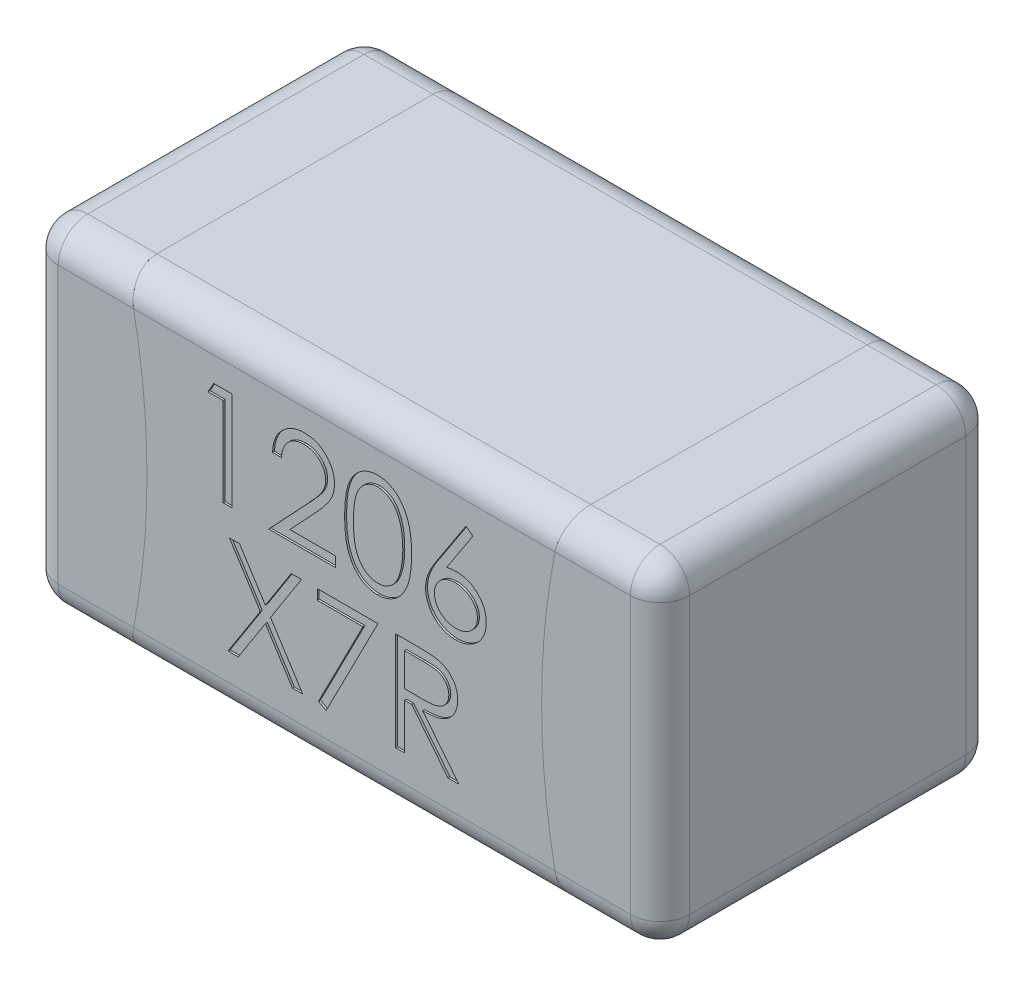
from build123d import *

# Parameters (mm, degrees)
EXTRUDE_1_DEPTH     = 1.7
EXTRUDE_1_2_DEPTH   = 1.7
EXTRUDE_2_DEPTH     = 1.7
FILLET_1_R          = 0.15
FILLET_2_R          = 0.15
FILLET_3_R          = 0.15
CUT_EXTRUDE_1_DEPTH = 0.01


with BuildPart() as part:
    # Эскиз1 → Бобышка-Вытянуть1 (new body)
    with BuildSketch(Plane.XY):
        with BuildLine():
            Line((-1.1, 0.85), (-1.6, 0.85))
            Line((-1.6, 0.85), (-1.6, -0.85))
            Line((-1.6, -0.85), (-1.1, -0.85))
            ThreePointArc((-1.1, -0.85), (-1, 0), (-1.1, 0.85))
        make_face()
    extrude(amount=EXTRUDE_1_DEPTH)

    # Скругление2
    fillet_2_edges = [part.edges().sort_by_distance(p)[0] for p in [
        (-1.6, 0.85, 0.85),
        (-1.6, 0, 1.7),
        (-1.6, -0.85, 0.85),
        (-1.6, 0, 0),
        (-1.35, 0.85, 0),
        (-1.35, -0.85, 0),
        (-1.35, 0.85, 1.7),
        (-1.35, -0.85, 1.7),
    ]]
    fillet(fillet_2_edges, radius=FILLET_2_R)


with BuildPart() as body_2:
    # Эскиз1 → Extrude 1 2 (new body)
    with BuildSketch(Plane.XY):
        with BuildLine():
            Line((1.6, 0.85), (1.1, 0.85))
            ThreePointArc((1.1, 0.85), (1, 0), (1.1, -0.85))
            Line((1.1, -0.85), (1.6, -0.85))
            Line((1.6, -0.85), (1.6, 0.85))
        make_face()
    extrude(amount=EXTRUDE_1_2_DEPTH)

    # Скругление1
    fillet_1_edges = [body_2.edges().sort_by_distance(p)[0] for p in [
        (1.6, -0.85, 0.85),
        (1.6, 0, 1.7),
        (1.6, 0.85, 0.85),
        (1.6, 0, 0),
        (1.35, -0.85, 0),
        (1.35, -0.85, 1.7),
        (1.35, 0.85, 0),
        (1.35, 0.85, 1.7),
    ]]
    fillet(fillet_1_edges, radius=FILLET_1_R)


with BuildPart() as body_3:
    # Эскиз1<3> → Бобышка-Вытянуть2 (new body)
    with BuildSketch(Plane.XY):
        with BuildLine():
            Line((1.1, 0.85), (-1.1, 0.85))
            ThreePointArc((-1.1, 0.85), (-1, 0), (-1.1, -0.85))
            Line((-1.1, -0.85), (1.1, -0.85))
            ThreePointArc((1.1, -0.85), (1, 0), (1.1, 0.85))
        make_face()
    extrude(amount=EXTRUDE_2_DEPTH)

    # Скругление3
    fillet_3_edges = [body_3.edges().sort_by_distance(p)[0] for p in [
        (0, -0.85, 1.7),
        (0, -0.85, 0),
        (0, 0.85, 1.7),
        (0, 0.85, 0),
    ]]
    fillet(fillet_3_edges, radius=FILLET_3_R)

    # Эскиз2 → Вырез-Вытянуть1 (cut)
    # profile 1 of 7: a face of its own
    with BuildSketch(Plane.XY.offset(1.7)):
        Polygon((-0.66134935, 0.575439945), (-0.568901434, 0.575439945), (-0.568901434, 0.075439945), (-0.613773229, 0.075439945), (-0.613773229, 0.524157894), (-0.690696305, 0.524157894), align=None)
    # profile 2 of 7: a face of its own
    with BuildSketch(Plane.XY.offset(1.7)):
        with BuildLine():
            Line((-0.318901434, 0.421593791), (-0.363773229, 0.421593791))
            add(Edge.make_bspline(
                [(-0.363773229, 0.421593791), (-0.363480778, 0.427546775), (-0.362906413, 0.439238277), (-0.360216658, 0.456284549), (-0.356367961, 0.472578092), (-0.350926325, 0.48798808), (-0.344168285, 0.502650767), (-0.336063995, 0.516507912), (-0.326464874, 0.529506653), (-0.315578198, 0.541526488), (-0.303754106, 0.552553283), (-0.290996115, 0.562075461), (-0.277589682, 0.570120843), (-0.263575483, 0.576846734), (-0.248795402, 0.581895284), (-0.233383565, 0.585641232), (-0.21727226, 0.587894996), (-0.206295114, 0.588137251), (-0.200712331, 0.588260458)],
                knots=[0, 0, 0, 0, 1.10065271, 2.161652631, 3.183658789, 4.190468796, 5.17591951, 6.163126047, 7.15150782, 8.156236427, 9.156009102, 10.134482811, 11.092018607, 12.041330605, 13.001268258, 13.972401359, 14.968799086, 16, 16, 16, 16], degree=3))
            add(Edge.make_bspline(
                [(-0.200712331, 0.588260458), (-0.195229749, 0.588132107), (-0.184456671, 0.587879902), (-0.168733526, 0.58571404), (-0.153765341, 0.582321813), (-0.139581375, 0.577562468), (-0.126294794, 0.571164693), (-0.113805788, 0.56347933), (-0.101965672, 0.554590783), (-0.09130756, 0.544125952), (-0.081520692, 0.532954183), (-0.073077512, 0.521027339), (-0.06584706, 0.50870887), (-0.059820249, 0.495904841), (-0.055383658, 0.482494694), (-0.052015342, 0.468673665), (-0.050111426, 0.454298692), (-0.049819223, 0.444569184), (-0.049670664, 0.439622637)],
                knots=[0, 0, 0, 0, 1.111607364, 2.184268762, 3.212621178, 4.221274766, 5.211760367, 6.196651075, 7.1921475, 8.207485113, 9.220403448, 10.201281604, 11.166441695, 12.114753415, 13.065576456, 14.026450734, 14.996634279, 16, 16, 16, 16], degree=3))
            add(Edge.make_bspline(
                [(-0.049670664, 0.439622637), (-0.049912559, 0.432658661), (-0.050392104, 0.418852916), (-0.054494157, 0.398565078), (-0.060900802, 0.378908876), (-0.06861471, 0.363089261), (-0.076396488, 0.350341619), (-0.083408989, 0.33984609), (-0.091618248, 0.328545309), (-0.101143747, 0.316477118), (-0.111788443, 0.303546988), (-0.123648752, 0.289762732), (-0.13680925, 0.275266765), (-0.146046178, 0.265365965), (-0.150832523, 0.260235618)],
                knots=[0, 0, 0, 0, 1.184426356, 2.348067706, 3.509069118, 4.696110526, 5.333549288, 6.050745305, 6.844228056, 7.710549037, 8.667450064, 9.695053472, 10.805634456, 12, 12, 12, 12], degree=3))
            Line((-0.150832523, 0.260235618), (-0.275932684, 0.126721996))
            Line((-0.275932684, 0.126721996), (-0.043260408, 0.126721996))
            Line((-0.043260408, 0.126721996), (-0.043260408, 0.075439945))
            Line((-0.043260408, 0.075439945), (-0.383003998, 0.075439945))
            Line((-0.383003998, 0.075439945), (-0.189093741, 0.282371035))
            add(Edge.make_bspline(
                [(-0.189093741, 0.282371035), (-0.184372615, 0.287299364), (-0.175304297, 0.296765676), (-0.162478214, 0.310586099), (-0.150958359, 0.323407462), (-0.14067016, 0.335205541), (-0.131836802, 0.346152907), (-0.123997912, 0.355895008), (-0.117717113, 0.364859929), (-0.110900628, 0.375251446), (-0.10429863, 0.38793892), (-0.098625437, 0.403443732), (-0.095166173, 0.419404768), (-0.094751196, 0.430190774), (-0.094542459, 0.435616227)],
                knots=[0, 0, 0, 0, 1.329631726, 2.553950428, 3.673215718, 4.687767853, 5.603093632, 6.413772471, 7.123043292, 7.734684054, 8.834405432, 9.900288307, 10.943827018, 12, 12, 12, 12], degree=3))
            add(Edge.make_bspline(
                [(-0.094542459, 0.435616227), (-0.09463328, 0.439027855), (-0.094812269, 0.44575152), (-0.09639194, 0.455609485), (-0.098779155, 0.465118744), (-0.102199906, 0.474308547), (-0.106715155, 0.483086497), (-0.112211352, 0.49146328), (-0.11855279, 0.499561704), (-0.125888685, 0.507155032), (-0.133947474, 0.51410949), (-0.142460938, 0.520270074), (-0.151468096, 0.525418518), (-0.160930971, 0.529639018), (-0.17082318, 0.532949786), (-0.181163858, 0.535243869), (-0.191924432, 0.536684224), (-0.199272074, 0.536879106), (-0.203016017, 0.536978406)],
                knots=[0, 0, 0, 0, 0.991446411, 1.95395049, 2.89581595, 3.838931463, 4.798493298, 5.75982156, 6.748411868, 7.785213223, 8.824556874, 9.840280684, 10.836137867, 11.835679398, 12.848801643, 13.863922112, 14.911575587, 16, 16, 16, 16], degree=3))
            add(Edge.make_bspline(
                [(-0.203016017, 0.536978406), (-0.206926136, 0.536876259), (-0.214604964, 0.536675658), (-0.225879112, 0.53527242), (-0.236634223, 0.532851586), (-0.246897352, 0.529540633), (-0.256685864, 0.525332268), (-0.265952156, 0.520090591), (-0.274675426, 0.513835806), (-0.282872072, 0.506744298), (-0.290424069, 0.498848926), (-0.297059337, 0.490047503), (-0.302857053, 0.480500729), (-0.307915515, 0.470234365), (-0.312023471, 0.459155254), (-0.315162492, 0.447302724), (-0.317646328, 0.434728241), (-0.318476116, 0.426044658), (-0.318901434, 0.421593791)],
                knots=[0, 0, 0, 0, 1.031018746, 2.02475058, 2.990194455, 3.934040569, 4.864654155, 5.795059489, 6.735614925, 7.690564532, 8.649604399, 9.611025574, 10.590972636, 11.591080095, 12.624614302, 13.701020113, 14.821632451, 16, 16, 16, 16], degree=3))
        make_face()
    # profile 3 of 7: a face of its own
    with BuildSketch(Plane.XY.offset(1.7)):
        with BuildLine():
            add(Edge.make_bspline(
                [(0.001611387, 0.325239624), (0.001658247, 0.333253537), (0.001749272, 0.348820677), (0.002761904, 0.371504198), (0.004444096, 0.392784239), (0.006749435, 0.41266182), (0.00955486, 0.431142072), (0.01329993, 0.448175609), (0.017558902, 0.463841267), (0.022494965, 0.478190131), (0.028064649, 0.491415517), (0.034126687, 0.503761974), (0.040921657, 0.515210822), (0.048061216, 0.525944792), (0.055834369, 0.535788177), (0.064019911, 0.544879986), (0.072937322, 0.553010093), (0.082283466, 0.560416708), (0.092142961, 0.566909489), (0.10223477, 0.572628452), (0.112628357, 0.577514147), (0.123352097, 0.581355638), (0.134309605, 0.584528616), (0.145539186, 0.586698466), (0.157059381, 0.588063739), (0.164835301, 0.588194262), (0.168778855, 0.588260458)],
                knots=[0, 0, 0, 0, 1.646270934, 3.197905019, 4.663502075, 6.030701355, 7.308322542, 8.50163776, 9.611534131, 10.641858119, 11.616356847, 12.558055219, 13.465016945, 14.349605745, 15.204443733, 16.039544428, 16.859896111, 17.680448484, 18.487036065, 19.28249412, 20.06191084, 20.843045899, 21.620316918, 22.403196591, 23.190181807, 24, 24, 24, 24], degree=3))
            add(Edge.make_bspline(
                [(0.168778855, 0.588260458), (0.172755352, 0.58819077), (0.180663353, 0.588052183), (0.192354835, 0.586720191), (0.203776218, 0.58451003), (0.214878809, 0.581378462), (0.225753808, 0.577493366), (0.236316152, 0.572623778), (0.246631449, 0.566955368), (0.256535776, 0.560294814), (0.266137864, 0.552868775), (0.275201858, 0.544474108), (0.283728585, 0.535195576), (0.291825057, 0.525132453), (0.299261571, 0.514091727), (0.30634349, 0.502265425), (0.312682352, 0.48944673), (0.318787306, 0.47584952), (0.324056875, 0.461097569), (0.328809196, 0.445274032), (0.332649049, 0.428192005), (0.335847516, 0.409941113), (0.338325358, 0.39045433), (0.340130022, 0.369773428), (0.341083319, 0.3478848), (0.341262848, 0.332919393), (0.341354977, 0.325239624)],
                knots=[0, 0, 0, 0, 0.810914788, 1.612654377, 2.396697861, 3.181598691, 3.963628158, 4.749916497, 5.551656086, 6.361998678, 7.18212741, 8.025565596, 8.878627764, 9.750805457, 10.657531673, 11.591944965, 12.560506719, 13.57287815, 14.630710178, 15.753379473, 16.941251878, 18.199788006, 19.531962791, 20.947069417, 22.433333509, 24, 24, 24, 24], degree=3))
            add(Edge.make_bspline(
                [(0.341354977, 0.325239624), (0.341261893, 0.317593352), (0.341080524, 0.302694901), (0.340140708, 0.280904762), (0.338289475, 0.260333613), (0.335973763, 0.240932118), (0.332766482, 0.22278103), (0.328822887, 0.205817537), (0.32444427, 0.189968384), (0.319039299, 0.175363411), (0.313123483, 0.161798879), (0.306687027, 0.149132144), (0.299791337, 0.137251245), (0.292278659, 0.126251281), (0.284271029, 0.11605433), (0.275597059, 0.106840384), (0.266501261, 0.098387431), (0.256870916, 0.09086577), (0.246812123, 0.084282226), (0.236532255, 0.078394533), (0.225848914, 0.073647006), (0.215004207, 0.069570571), (0.203843012, 0.066456221), (0.192379242, 0.064302813), (0.180671208, 0.062792549), (0.172756699, 0.062677337), (0.168778855, 0.062619432)],
                knots=[0, 0, 0, 0, 1.561518951, 3.042555995, 4.452378317, 5.7783523, 7.031515105, 8.214008947, 9.334062868, 10.386615937, 11.391082383, 12.354592575, 13.286541444, 14.194233754, 15.072674879, 15.931287219, 16.775624067, 17.606195743, 18.42308326, 19.229000347, 20.022332153, 20.807536673, 21.593273796, 22.3848459, 23.188221202, 24, 24, 24, 24], degree=3))
            add(Edge.make_bspline(
                [(0.168778855, 0.062619432), (0.16483541, 0.062686054), (0.157059706, 0.06281742), (0.145537931, 0.064176525), (0.134354725, 0.066361597), (0.123454903, 0.069421111), (0.112782544, 0.073166088), (0.102483074, 0.078045186), (0.092441977, 0.083664338), (0.08268604, 0.090063684), (0.073398588, 0.097395353), (0.064527359, 0.105504537), (0.056295214, 0.114593596), (0.0486332, 0.124519014), (0.041351187, 0.135189477), (0.034652705, 0.146750673), (0.028456869, 0.15915676), (0.022793513, 0.17248789), (0.017772276, 0.186938594), (0.013336889, 0.202674191), (0.009834866, 0.219833568), (0.006837301, 0.238278906), (0.004419532, 0.258089468), (0.002768914, 0.279276007), (0.001748726, 0.301825323), (0.001658002, 0.317292434), (0.001611387, 0.325239624)],
                knots=[0, 0, 0, 0, 0.810891512, 1.598919785, 2.382837074, 3.152667961, 3.926044502, 4.706494248, 5.493654104, 6.291793342, 7.103789334, 7.925228297, 8.761435821, 9.622817696, 10.50288917, 11.416980706, 12.369136599, 13.353924996, 14.394355917, 15.514179734, 16.714354668, 17.994756427, 19.357759367, 20.818452758, 22.365282078, 24, 24, 24, 24], degree=3))
        make_face()
        with BuildLine():
            add(Edge.make_bspline(
                [(0.046483182, 0.325439945), (0.046500246, 0.318761559), (0.046533363, 0.305800124), (0.047398535, 0.286965373), (0.048577139, 0.269398183), (0.050097325, 0.253076249), (0.052354889, 0.238054819), (0.05488443, 0.224230578), (0.057962728, 0.211676687), (0.061604874, 0.200307), (0.065753316, 0.189928562), (0.070282725, 0.180271245), (0.075148543, 0.171220969), (0.080594136, 0.162859025), (0.086524859, 0.155158144), (0.092806753, 0.147982025), (0.099674265, 0.141582456), (0.1091748, 0.133907191), (0.121717153, 0.125975887), (0.137520076, 0.119069302), (0.153758426, 0.114728951), (0.164780033, 0.114176986), (0.170281259, 0.113901483)],
                knots=[0, 0, 0, 0, 1.459021318, 2.831673884, 4.118529203, 5.306027144, 6.411944654, 7.436330062, 8.375795394, 9.233974572, 10.042671642, 10.816086306, 11.563610507, 12.285937304, 12.993564865, 13.685989202, 14.367179055, 15.041617293, 16.353048772, 17.594441528, 18.799311195, 20, 20, 20, 20], degree=3))
            add(Edge.make_bspline(
                [(0.170281259, 0.113901483), (0.175818069, 0.114129738), (0.186880258, 0.114585775), (0.203042229, 0.118985595), (0.218732267, 0.125624101), (0.231028259, 0.133473744), (0.240382908, 0.14094922), (0.247085335, 0.147322741), (0.253237056, 0.154459293), (0.259071638, 0.162159193), (0.264422935, 0.170569548), (0.269289097, 0.179649916), (0.273729575, 0.189425512), (0.276259439, 0.196249761), (0.277552893, 0.199738823)],
                knots=[0, 0, 0, 0, 1.353760809, 2.704726607, 4.075137775, 5.516104923, 6.260822281, 7.007110065, 7.778089737, 8.566572457, 9.372053459, 10.217411131, 11.088608312, 12, 12, 12, 12], degree=3))
            add(Edge.make_bspline(
                [(0.277552893, 0.199738823), (0.279060289, 0.204200214), (0.282120948, 0.213258752), (0.286065487, 0.227310702), (0.289171973, 0.242053954), (0.291966739, 0.2574004), (0.293874318, 0.273463214), (0.29540972, 0.290192698), (0.296314104, 0.307601464), (0.296426212, 0.319429319), (0.296483182, 0.325439945)],
                knots=[0, 0, 0, 0, 0.884706709, 1.796334032, 2.740027952, 3.714592787, 4.726048262, 5.777819803, 6.87074269, 8, 8, 8, 8], degree=3))
            add(Edge.make_bspline(
                [(0.296483182, 0.325439945), (0.296404583, 0.331449598), (0.296250828, 0.343205764), (0.295663115, 0.360422647), (0.294145462, 0.376775185), (0.292459873, 0.392333824), (0.289974556, 0.407012438), (0.287294869, 0.42093391), (0.283694696, 0.433925771), (0.279849014, 0.446191426), (0.275447529, 0.457591519), (0.270602424, 0.468179203), (0.265427887, 0.478005592), (0.259807567, 0.487043727), (0.253808184, 0.49533409), (0.247271391, 0.502710461), (0.240456481, 0.509401456), (0.230911168, 0.517038966), (0.218414841, 0.524826351), (0.202865463, 0.531992888), (0.186683942, 0.536108359), (0.175744878, 0.5366886), (0.170281259, 0.536978406)],
                knots=[0, 0, 0, 0, 1.31362396, 2.569729283, 3.763502607, 4.902122613, 5.988968491, 7.01645872, 7.998833611, 8.933434873, 9.825090667, 10.667526885, 11.477055099, 12.250526234, 12.991942729, 13.710640831, 14.402115721, 15.076753259, 16.378508321, 17.609869233, 18.806226677, 20, 20, 20, 20], degree=3))
            add(Edge.make_bspline(
                [(0.170281259, 0.536978406), (0.164751174, 0.5366882), (0.15368093, 0.536107258), (0.137331223, 0.532008221), (0.121659172, 0.524863512), (0.10919589, 0.517013173), (0.099643921, 0.509536271), (0.092917822, 0.503052492), (0.086611226, 0.49596017), (0.080801554, 0.488188468), (0.075360228, 0.479836273), (0.070362941, 0.470837878), (0.065860465, 0.461147683), (0.061705531, 0.450773906), (0.058052276, 0.4394052), (0.055038852, 0.426866772), (0.052254988, 0.413086502), (0.050284235, 0.397983715), (0.04853227, 0.381657693), (0.047406363, 0.364046648), (0.046530469, 0.345180308), (0.04649926, 0.332151857), (0.046483182, 0.325439945)],
                knots=[0, 0, 0, 0, 1.207732386, 2.417664972, 3.655092373, 4.956220595, 5.625982001, 6.301752483, 6.994047911, 7.697131622, 8.419323945, 9.170223765, 9.943494443, 10.752040957, 11.610060368, 12.549350801, 13.567764191, 14.679664412, 15.874934091, 17.154273443, 18.533957287, 20, 20, 20, 20], degree=3))
        make_face(mode=Mode.SUBTRACT)
    # profile 4 of 7: a face of its own
    with BuildSketch(Plane.XY.offset(1.7)):
        with BuildLine():
            Line((0.616996002, 0.588260458), (0.651551291, 0.561117028))
            Line((0.651551291, 0.561117028), (0.519439912, 0.359093791))
            add(Edge.make_bspline(
                [(0.519439912, 0.359093791), (0.528235666, 0.360495771), (0.545392779, 0.363230492), (0.562759336, 0.363681627), (0.571222765, 0.363901483)],
                knots=[0, 0, 0, 0, 1.025318673, 2, 2, 2, 2], degree=3))
            add(Edge.make_bspline(
                [(0.571222765, 0.363901483), (0.57630455, 0.363764896), (0.586307893, 0.363496028), (0.600994579, 0.361426906), (0.615107284, 0.358166176), (0.628587515, 0.353412996), (0.641483655, 0.347341232), (0.653869711, 0.34006425), (0.665512856, 0.331206296), (0.676563024, 0.321311302), (0.686595467, 0.310351733), (0.69547776, 0.29872297), (0.702938731, 0.28643713), (0.708992148, 0.273500435), (0.713692845, 0.259932827), (0.717119651, 0.245751664), (0.719145307, 0.230947168), (0.719420378, 0.220878857), (0.719560105, 0.215764464)],
                knots=[0, 0, 0, 0, 1.04369286, 2.054478336, 3.041073146, 4.015093852, 4.984733326, 5.965804835, 6.960378782, 7.985147595, 9.009457201, 10.008161701, 10.986880575, 11.956520048, 12.937015923, 13.931873656, 14.949455224, 16, 16, 16, 16], degree=3))
            add(Edge.make_bspline(
                [(0.719560105, 0.215764464), (0.719356804, 0.208767364), (0.718956756, 0.194998726), (0.7149705, 0.17494491), (0.708776265, 0.155840265), (0.699922332, 0.137989812), (0.688924849, 0.121418017), (0.675513764, 0.106734379), (0.660164695, 0.093638659), (0.642809438, 0.082687713), (0.624131871, 0.07374442), (0.604510157, 0.067320814), (0.584134851, 0.063366033), (0.570305621, 0.062870233), (0.563310105, 0.062619432)],
                knots=[0, 0, 0, 0, 1.031375318, 2.029502543, 3.004789286, 3.987476834, 4.960371455, 5.9300674, 6.912260825, 7.929083631, 8.949397511, 9.960523116, 10.96833055, 12, 12, 12, 12], degree=3))
            add(Edge.make_bspline(
                [(0.563310105, 0.062619432), (0.556582005, 0.062837747), (0.543254816, 0.063270191), (0.523650131, 0.067122468), (0.504812558, 0.07336634), (0.486874075, 0.08196838), (0.470256844, 0.092833791), (0.455390325, 0.105914117), (0.442348643, 0.120929755), (0.431495125, 0.137878376), (0.422886735, 0.156091227), (0.416431031, 0.175082249), (0.41266014, 0.194782247), (0.412133203, 0.208136695), (0.411867797, 0.214863022)],
                knots=[0, 0, 0, 0, 1.012016664, 2.004627821, 2.994792927, 3.992885782, 4.990978636, 5.973936114, 6.964471063, 7.975201453, 8.993600317, 9.990122807, 10.98767138, 12, 12, 12, 12], degree=3))
            add(Edge.make_bspline(
                [(0.411867797, 0.214863022), (0.412036575, 0.220012248), (0.412381187, 0.230525984), (0.414787386, 0.246449416), (0.418653785, 0.262742428), (0.42298382, 0.276564456), (0.427558907, 0.28788753), (0.431366413, 0.2970166), (0.436105555, 0.30641104), (0.441158895, 0.316392988), (0.446981305, 0.326705192), (0.453312112, 0.337520002), (0.460326348, 0.34866542), (0.465243514, 0.356228877), (0.46775722, 0.360095394)],
                knots=[0, 0, 0, 0, 1.173818275, 2.396712641, 3.66331629, 4.989737886, 5.693666774, 6.447286557, 7.243889047, 8.091586357, 8.998013824, 9.943181721, 10.948533338, 12, 12, 12, 12], degree=3))
            Line((0.46775722, 0.360095394), (0.616996002, 0.588260458))
        make_face()
        with BuildLine():
            add(Edge.make_bspline(
                [(0.561807701, 0.312619432), (0.557998809, 0.312508283), (0.550558936, 0.312291176), (0.539643591, 0.311030426), (0.529313127, 0.308656274), (0.519430679, 0.305632512), (0.510181007, 0.301474932), (0.501496887, 0.296424675), (0.493344737, 0.290478793), (0.485809944, 0.28372152), (0.478978563, 0.276323229), (0.473095545, 0.268399012), (0.468020916, 0.26013984), (0.463894942, 0.251476705), (0.460682074, 0.24241292), (0.458358038, 0.23299017), (0.457064645, 0.223145269), (0.456849469, 0.216469197), (0.456739592, 0.213060137)],
                knots=[0, 0, 0, 0, 1.129588631, 2.206414736, 3.251139165, 4.268635594, 5.265702196, 6.250456724, 7.242448911, 8.251968645, 9.246821453, 10.222880186, 11.173611482, 12.116736599, 13.062300278, 14.020270554, 14.989073742, 16, 16, 16, 16], degree=3))
            add(Edge.make_bspline(
                [(0.456739592, 0.213060137), (0.456829072, 0.209681569), (0.45700453, 0.203056699), (0.458597718, 0.193293959), (0.461031301, 0.183898972), (0.464651358, 0.174920172), (0.468969485, 0.166220698), (0.474670245, 0.158115657), (0.480986929, 0.15011279), (0.488537491, 0.142826866), (0.496640828, 0.136047348), (0.505298143, 0.130121597), (0.514320995, 0.125052144), (0.523831198, 0.12107913), (0.533693824, 0.117818518), (0.543991046, 0.115524021), (0.554730025, 0.114226803), (0.562004588, 0.114011346), (0.565713951, 0.113901483)],
                knots=[0, 0, 0, 0, 0.989467248, 1.94019797, 2.891935182, 3.827694429, 4.772920941, 5.730924762, 6.725747692, 7.756678648, 8.79901574, 9.819492441, 10.826891316, 11.826466727, 12.835195252, 13.867842842, 14.912794438, 16, 16, 16, 16], degree=3))
            add(Edge.make_bspline(
                [(0.565713951, 0.113901483), (0.569423308, 0.114011355), (0.576697859, 0.114226828), (0.587436924, 0.115523924), (0.597733827, 0.117818873), (0.607597614, 0.12107784), (0.617103533, 0.125056928), (0.626118493, 0.130090059), (0.634693935, 0.13608379), (0.642802592, 0.14281528), (0.650321726, 0.150154259), (0.656789909, 0.158044219), (0.662316085, 0.166286204), (0.666806683, 0.174885903), (0.670386867, 0.183904401), (0.672832791, 0.193292504), (0.67442269, 0.203057079), (0.674598599, 0.209681697), (0.67468831, 0.213060137)],
                knots=[0, 0, 0, 0, 1.087397944, 2.132534446, 3.165364764, 4.174271784, 5.174024072, 6.181601208, 7.194203697, 8.236725232, 9.267838612, 10.269026844, 11.221737037, 12.171628256, 13.107553087, 14.05945871, 15.010357665, 16, 16, 16, 16], degree=3))
            add(Edge.make_bspline(
                [(0.67468831, 0.213060137), (0.674609697, 0.216473644), (0.674455404, 0.223173249), (0.672710269, 0.232985766), (0.67028993, 0.242460795), (0.666635211, 0.251538788), (0.661887133, 0.260183921), (0.656103789, 0.268439864), (0.649413422, 0.276369913), (0.641685202, 0.283736029), (0.633272312, 0.290471326), (0.624327228, 0.296416976), (0.614968946, 0.30143483), (0.605206954, 0.305621559), (0.5949294, 0.308642913), (0.584302208, 0.311021947), (0.573189459, 0.31228795), (0.565649944, 0.312507531), (0.561807701, 0.312619432)],
                knots=[0, 0, 0, 0, 0.978206639, 1.919901502, 2.851605144, 3.780102724, 4.718870031, 5.675451981, 6.667674623, 7.690630536, 8.733308323, 9.756129687, 10.767539656, 11.776269907, 12.797430371, 13.836405707, 14.897401972, 16, 16, 16, 16], degree=3))
        make_face(mode=Mode.SUBTRACT)
    # profile 5 of 7: a face of its own
    with BuildSketch(Plane.XY.offset(1.7)):
        Polygon((-0.582466305, -0.062820741), (-0.530683452, -0.062820741), (-0.399773997, -0.267347985), (-0.268864542, -0.062820741), (-0.217081689, -0.062820741), (-0.373832491, -0.307812728), (-0.210671433, -0.562820741), (-0.262454285, -0.562820741), (-0.399773997, -0.348277472), (-0.537093708, -0.562820741), (-0.588876561, -0.562820741), (-0.425615343, -0.307812728), align=None)
    # profile 6 of 7: a face of its own
    with BuildSketch(Plane.XY.offset(1.7)):
        Polygon((-0.136953484, -0.062820741), (0.170738824, -0.062820741), (-0.092081689, -0.575641254), (-0.130843708, -0.554307119), (0.094817349, -0.114102792), (-0.136953484, -0.114102792), align=None)
    # profile 7 of 7: a face of its own
    with BuildSketch(Plane.XY.offset(1.7)):
        with BuildLine():
            Line((0.260482413, -0.062820741), (0.360542509, -0.062820741))
            add(Edge.make_bspline(
                [(0.360542509, -0.062820741), (0.367219814, -0.062842968), (0.380040977, -0.062885645), (0.398408587, -0.063123611), (0.415098172, -0.063805662), (0.430101007, -0.064392603), (0.443416814, -0.06546288), (0.455086427, -0.06648583), (0.465056098, -0.067824924), (0.47109122, -0.069068556), (0.473823759, -0.069631639)],
                knots=[0, 0, 0, 0, 1.410062039, 2.707475311, 3.878576406, 4.937260626, 5.877586885, 6.699081471, 7.410979367, 8, 8, 8, 8], degree=3))
            add(Edge.make_bspline(
                [(0.473823759, -0.069631639), (0.477481849, -0.070535462), (0.48471999, -0.072323828), (0.495141428, -0.076103771), (0.505072046, -0.080478003), (0.514470592, -0.085615678), (0.523289991, -0.091554932), (0.531621178, -0.098193235), (0.539501959, -0.105494265), (0.54661362, -0.113642099), (0.553319199, -0.122190172), (0.558974717, -0.131433566), (0.563849928, -0.141099498), (0.567731431, -0.151286272), (0.570856855, -0.161895097), (0.573060604, -0.173022068), (0.574382202, -0.184616493), (0.574516753, -0.192524765), (0.574584977, -0.196534683)],
                knots=[0, 0, 0, 0, 1.027469482, 2.033020251, 3.019912614, 3.986113645, 4.951240523, 5.91722682, 6.890402269, 7.87763091, 8.8651537, 9.85103654, 10.82876324, 11.815024772, 12.821070561, 13.842952187, 14.906261191, 16, 16, 16, 16], degree=3))
            add(Edge.make_bspline(
                [(0.574584977, -0.196534683), (0.574375121, -0.203196841), (0.573965635, -0.216196437), (0.570147763, -0.235062277), (0.563893975, -0.25266075), (0.555276362, -0.268969699), (0.544302151, -0.283671219), (0.531112896, -0.296584142), (0.515701237, -0.307389843), (0.501354192, -0.314883101), (0.488680735, -0.319682088), (0.478247404, -0.323058711), (0.466866407, -0.325667563), (0.454646788, -0.328004725), (0.441537694, -0.329769252), (0.427570546, -0.331061623), (0.412735381, -0.331869344), (0.402544086, -0.331989631), (0.397301324, -0.33205151)],
                knots=[0, 0, 0, 0, 1.260483769, 2.459530307, 3.627416485, 4.787058657, 5.939039949, 7.08810263, 8.267026773, 9.491475466, 10.141966685, 10.831826277, 11.566392101, 12.351337768, 13.187381173, 14.07005841, 15.007169909, 16, 16, 16, 16], degree=3))
            Line((0.397301324, -0.33205151), (0.580995234, -0.562820741))
            Line((0.580995234, -0.562820741), (0.525506452, -0.562820741))
            Line((0.525506452, -0.562820741), (0.341812542, -0.33205151))
            Line((0.341812542, -0.33205151), (0.305354208, -0.33205151))
            Line((0.305354208, -0.33205151), (0.305354208, -0.562820741))
            Line((0.305354208, -0.562820741), (0.260482413, -0.562820741))
            Line((0.260482413, -0.562820741), (0.260482413, -0.062820741))
        make_face()
        with BuildLine():
            Line((0.305354208, -0.114102792), (0.305354208, -0.280769459))
            Line((0.305354208, -0.280769459), (0.396900683, -0.281470581))
            add(Edge.make_bspline(
                [(0.396900683, -0.281470581), (0.401174974, -0.281472472), (0.409459768, -0.281476137), (0.421445577, -0.280905598), (0.432605593, -0.280256552), (0.442897129, -0.279263788), (0.452324783, -0.27798435), (0.460883842, -0.276383923), (0.468588278, -0.274519343), (0.477573783, -0.271633396), (0.487607573, -0.267061108), (0.498512068, -0.260408894), (0.507798116, -0.252041877), (0.515643525, -0.24247424), (0.521947729, -0.231954776), (0.526392308, -0.220609581), (0.529212657, -0.208725067), (0.529545307, -0.200556766), (0.529713183, -0.196434523)],
                knots=[0, 0, 0, 0, 1.146690395, 2.22261258, 3.21895312, 4.145990853, 4.996080663, 5.770904154, 6.481378293, 7.121626537, 8.300444488, 9.431385265, 10.535395872, 11.636531494, 12.74115979, 13.810798291, 14.895190096, 16, 16, 16, 16], degree=3))
            add(Edge.make_bspline(
                [(0.529713183, -0.196434523), (0.529541451, -0.192413584), (0.529201142, -0.18444555), (0.526422746, -0.17278042), (0.521724263, -0.161770856), (0.515392515, -0.151461643), (0.50767835, -0.142103681), (0.498632948, -0.134096945), (0.488503634, -0.127489879), (0.47903632, -0.123267824), (0.47057429, -0.120679274), (0.463227196, -0.118857679), (0.454925556, -0.117394183), (0.445629062, -0.116221603), (0.4353774, -0.115213754), (0.424118736, -0.114534929), (0.411927767, -0.114132948), (0.403478206, -0.114113078), (0.399104208, -0.114102792)],
                knots=[0, 0, 0, 0, 1.101028733, 2.181837193, 3.264309656, 4.369019818, 5.486613113, 6.575447106, 7.666700264, 8.788928104, 9.402425223, 10.0903467, 10.862060571, 11.710948788, 12.657782767, 13.684531032, 14.801375019, 16, 16, 16, 16], degree=3))
            Line((0.399104208, -0.114102792), (0.305354208, -0.114102792))
        make_face(mode=Mode.SUBTRACT)
    extrude(amount=-CUT_EXTRUDE_1_DEPTH, mode=Mode.SUBTRACT)


solid = Compound([part.part, body_2.part, body_3.part])
